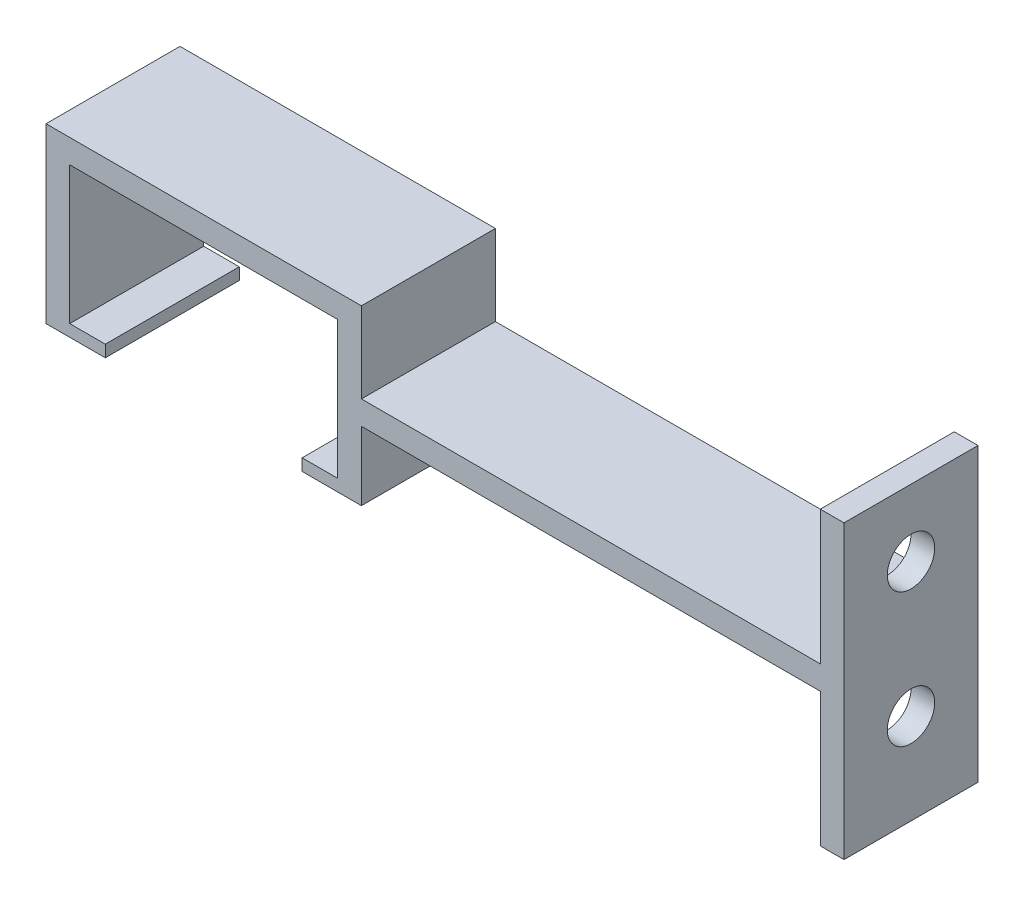
from build123d import *

# Parameters (mm, degrees)
BOSS_EXTRU_1_DEPTH      = 11.3
ESQUISSE2_W             = 8.6
ESQUISSE2_H             = 11.3
BOSS_EXTRU_2_DEPTH      = 1
ESQUISSE8_W             = 11.3
ESQUISSE8_H             = 1
BOSS_EXTRU_5_DEPTH      = 10
ESQUISSE9_W             = 2
ESQUISSE9_H             = 11.3
BOSS_EXTRU_6_DEPTH      = 7.8
ESQUISSE10_W            = 11.3
ESQUISSE10_H            = 2
BOSS_EXTRU_7_DEPTH      = 39.7
ESQUISSE11_W            = 2
ESQUISSE11_H            = 11.3
BOSS_EXTRU_8_DEPTH      = 11.3
ESQUISSE12_W            = 2
ESQUISSE12_H            = 11.3
BOSS_EXTRU_9_DEPTH      = 11.3
BOSS_EXTRU_10_DEPTH     = 11.3
ESQUISSE14_W            = 1
ESQUISSE14_H            = 11.3
BOSS_EXTRU_11_DEPTH     = 5.8
ESQUISSE16_W            = 11.3
ESQUISSE16_H            = 6.8
ENL_V_MAT_EXTRU_1_DEPTH = 1
ESQUISSE19_R            = 2
ENL_V_MAT_EXTRU_3_DEPTH = 10


with BuildPart() as part:
    # Esquisse1 → Boss.-Extru.1 (new body)
    with BuildSketch(Plane.XY):
        Polygon((-20.6, 1), (-20.6, 0), (-24.6, 0), (-24.6, 13.6), (0, 13.6), (0, 0), (-4, 0), (-4, 1), (-1, 1), (-1, 12.6), (-23.6, 12.6), (-23.6, 1), align=None)
    extrude(amount=BOSS_EXTRU_1_DEPTH)

    # Esquisse2 → Boss.-Extru.2 (add)
    with BuildSketch(Plane(origin=(0, 13.6, 0), x_dir=(1, 0, 0), z_dir=(0, 1, 0))):
        with Locations((-12.3, -5.65)):
            Rectangle(ESQUISSE2_W, ESQUISSE2_H)
    extrude(amount=BOSS_EXTRU_2_DEPTH)

    # Esquisse8 → Boss.-Extru.5 (add)
    with BuildSketch(Plane(origin=(-8, 0, 0), x_dir=(0, 0, -1), z_dir=(1, 0, 0))):
        with Locations((-5.65, 14.1)):
            Rectangle(ESQUISSE8_W, ESQUISSE8_H)
    extrude(amount=BOSS_EXTRU_5_DEPTH)

    # Esquisse9 → Boss.-Extru.6 (add)
    with BuildSketch(Plane.XZ.offset(-13.6)):
        with Locations((1, 5.65)):
            Rectangle(ESQUISSE9_W, ESQUISSE9_H)
    extrude(amount=BOSS_EXTRU_6_DEPTH)

    # Esquisse10 → Boss.-Extru.7 (add)
    with BuildSketch(Plane(origin=(2, 0, 0), x_dir=(0, 0, -1), z_dir=(1, 0, 0))):
        with Locations((-5.65, 6.8)):
            Rectangle(ESQUISSE10_W, ESQUISSE10_H)
    extrude(amount=BOSS_EXTRU_7_DEPTH)

    # Esquisse11 → Boss.-Extru.8 (add)
    with BuildSketch(Plane.XZ.offset(-5.8)):
        with Locations((40.7, 5.65)):
            Rectangle(ESQUISSE11_W, ESQUISSE11_H)
    extrude(amount=BOSS_EXTRU_8_DEPTH)

    # Esquisse12 → Boss.-Extru.9 (add)
    with BuildSketch(Plane(origin=(0, 7.8, 0), x_dir=(1, 0, 0), z_dir=(0, 1, 0))):
        with Locations((40.7, -5.65)):
            Rectangle(ESQUISSE12_W, ESQUISSE12_H)
    extrude(amount=BOSS_EXTRU_9_DEPTH)

    # Esquisse13 → Boss.-Extru.10 (add)
    with BuildSketch(Plane.XY.offset(11.3)):
        Polygon((-16.6, 14.6), (-25.6, 14.6), (-25.6, 0), (-24.6, 0), (-24.6, 13.6), (-16.6, 13.6), align=None)
    extrude(amount=-BOSS_EXTRU_10_DEPTH)

    # Esquisse14 → Boss.-Extru.11 (add)
    with BuildSketch(Plane.XZ.offset(-5.8)):
        with Locations((0.5, 5.65)):
            Rectangle(ESQUISSE14_W, ESQUISSE14_H)
    extrude(amount=BOSS_EXTRU_11_DEPTH)

    # Esquisse16 → Enlèv. mat.-Extru.1 (cut)
    with BuildSketch(Plane(origin=(2, 0, 0), x_dir=(0, 0, -1), z_dir=(1, 0, 0))):
        with Locations((-5.65, 11.2)):
            Rectangle(ESQUISSE16_W, ESQUISSE16_H)
    extrude(amount=-ENL_V_MAT_EXTRU_1_DEPTH, mode=Mode.SUBTRACT)

    # Esquisse19 → Enlèv. mat.-Extru.3 (cut)
    with BuildSketch(Plane(origin=(41.7, 0, 0), x_dir=(0, 0, -1), z_dir=(1, 0, 0))):
        with Locations((-5.65, 13.45)):
            Circle(ESQUISSE19_R)
        with Locations((-5.65, 2.15)):
            Circle(ESQUISSE19_R)
    extrude(amount=-ENL_V_MAT_EXTRU_3_DEPTH, mode=Mode.SUBTRACT)


solid = part.part
